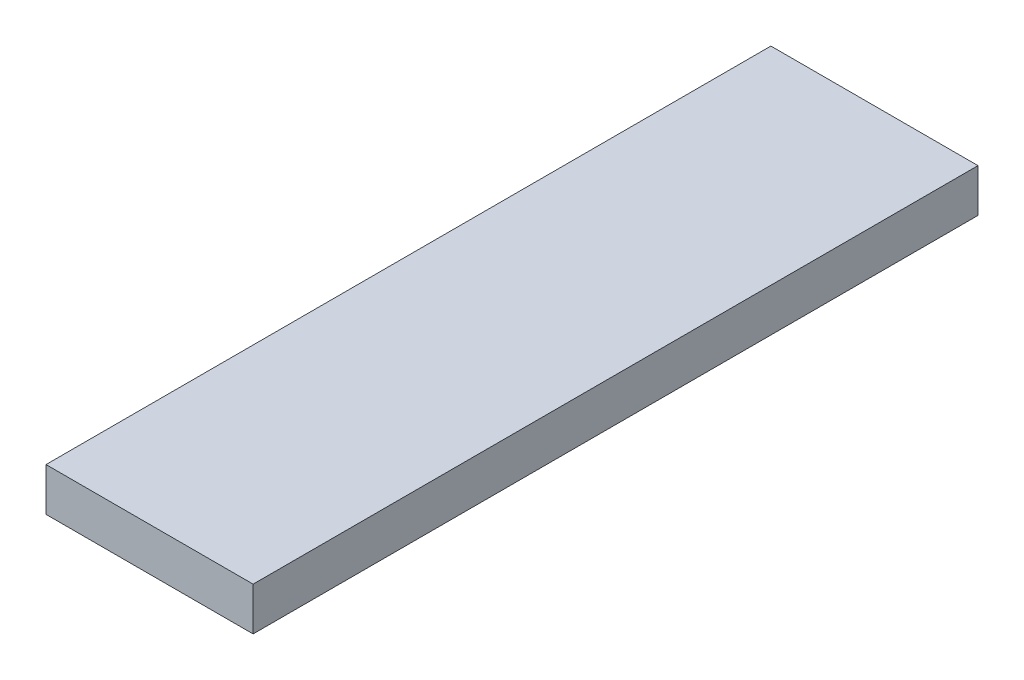
from build123d import *

# Parameters (mm, degrees)
SKETCH1_W           = 15.24
SKETCH1_H           = 3.175
BOSS_EXTRUDE1_DEPTH = 53.34


with BuildPart() as part:
    # Sketch1 → Boss-Extrude1 (new body)
    with BuildSketch(Plane.XY):
        with Locations((-7.62, 1.5875)):
            Rectangle(SKETCH1_W, SKETCH1_H)
    extrude(amount=BOSS_EXTRUDE1_DEPTH)


solid = part.part
